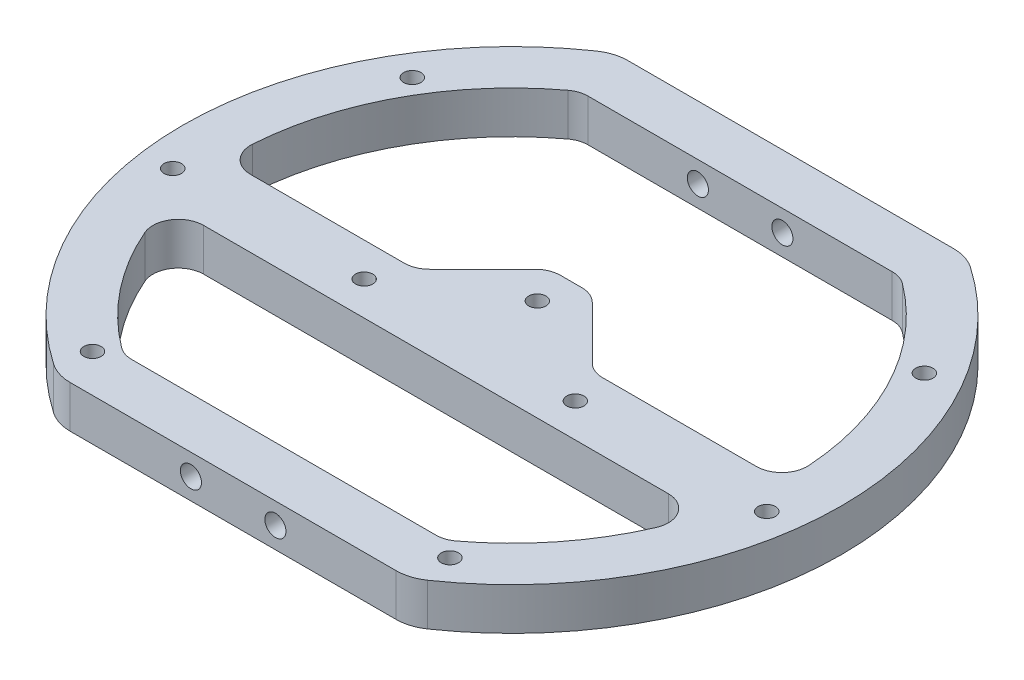
from build123d import *

# Parameters (mm, degrees)
BOSS_EXTRUDE1_DEPTH            = 5
FILLET1_R                      = 5
M3X0_5_TAPPED_HOLE1_AT_2_COUNT = 2
M3X0_5_TAPPED_HOLE1_AT_2_PITCH = 10
M2_5X0_45_TAPPED_HOLE2_D       = 2.05
CUT_EXTRUDE1_DEPTH             = 5
FILLET2_R                      = 3
M2_5X0_45_TAPPED_HOLE1_D       = 2.05


with BuildPart() as part:
    # Sketch1 → Boss-Extrude1 (new body)
    with BuildSketch(Plane(origin=(0, 0, 0), x_dir=(1, 0, 0), z_dir=(0, 1, 0))):
        with BuildLine():
            Line((-20.784609691, 33), (20.784609691, 33))
            ThreePointArc((20.784609691, 33), (39, 0), (20.784609691, -33))
            Line((20.784609691, -33), (-20.784609691, -33))
            ThreePointArc((-20.784609691, -33), (-39, 0), (-20.784609691, 33))
        make_face()
    extrude(amount=BOSS_EXTRUDE1_DEPTH)

    # Fillet1
    fillet1_edges = [part.edges().sort_by_distance(p)[0] for p in [
        (-20.784609691, 2.5, -33),
        (20.784609691, 2.5, -33),
        (20.784609691, 2.5, 33),
        (-20.784609691, 2.5, 33),
    ]]
    fillet(fillet1_edges, radius=FILLET1_R)

    # Sketch3 → M3x0.5 Tapped Hole1 (revolve, cut)
    with BuildSketch(Plane(origin=(-5, 2.5, 33), x_dir=(0, -1, 0), z_dir=(1, 0, 0))):
        Polygon((0, 0), (0, 8.251075774), (1.25, 7.5), (1.25, 0), align=None)
    m3x0_5_tapped_hole1 = revolve(axis=Axis((-5, 2.5, 39.35), (0, 0, -1)), mode=Mode.SUBTRACT)

    # M3x0.5 Tapped Hole1 at 2: M3x0.5 Tapped Hole1 ×2
    with Locations(*[(i * M3X0_5_TAPPED_HOLE1_AT_2_PITCH, 0, 0) for i in range(1, M3X0_5_TAPPED_HOLE1_AT_2_COUNT)]):
        add(m3x0_5_tapped_hole1, mode=Mode.SUBTRACT)

    # Mirror1: M3x0.5 Tapped Hole1 across plane
    add(m3x0_5_tapped_hole1.mirror(Plane.XY), mode=Mode.SUBTRACT)

    # Mirror1 copy 1 sketch → Mirror1 copy 1 (revolve, cut)
    with BuildSketch(Plane(origin=(5, 2.5, -33), x_dir=(0, -1, 0), z_dir=(1, 0, 0))):
        Polygon((0, 0), (0, -8.251075774), (1.25, -7.5), (1.25, 0), align=None)
    revolve(axis=Axis((5, 2.5, -39.35), (0, 0, -1)), mode=Mode.SUBTRACT)

    # M2.5x0.45 Tapped Hole2 (through all)
    with Locations(Plane(origin=(0, 0, 0), x_dir=(-1, 0, 0), z_dir=(0, -1, 0))):
        with Locations((12.5, -5), (-12.5, -5), (0, 3)):
            Hole(M2_5X0_45_TAPPED_HOLE2_D / 2)

    # Sketch6 → Cut-Extrude1 (cut)
    with BuildSketch(Plane.XZ):
        with BuildLine():
            Line((-31.749015733, 9), (31.749015733, 9))
            ThreePointArc((31.749015733, 9), (26.910919894, 19.099800796), (18.973665961, 27))
            Line((18.973665961, 27), (-18.973665961, 27))
            ThreePointArc((-18.973665961, 27), (-26.910919894, 19.099800796), (-31.749015733, 9))
        make_face()
        with BuildLine():
            Line((32.984845005, 1), (10.5, 1))
            Line((10.5, 1), (2.5, -7))
            Line((2.5, -7), (-2.5, -7))
            Line((-2.5, -7), (-10.5, 1))
            Line((-10.5, 1), (-32.984845005, 1))
            ThreePointArc((-32.984845005, 1), (-29.511382812, -14.767473872), (-18.973665961, -27))
            Line((-18.973665961, -27), (18.973665961, -27))
            ThreePointArc((18.973665961, -27), (29.511382812, -14.767473872), (32.984845005, 1))
        make_face()
    extrude(amount=-CUT_EXTRUDE1_DEPTH, mode=Mode.SUBTRACT)

    # Fillet2
    fillet2_edges = [part.edges().sort_by_distance(p)[0] for p in [
        (10.5, 2.5, 1),
        (2.5, 2.5, -7),
        (-2.5, 2.5, -7),
        (-10.5, 2.5, 1),
        (-32.984845005, 2.5, 1),
        (-18.973665961, 2.5, -27),
        (32.984845005, 2.5, 1),
        (-18.973665961, 2.5, 27),
        (31.749015733, 2.5, 9),
        (18.973665961, 2.5, 27),
        (-31.749015733, 2.5, 9),
        (18.973665961, 2.5, -27),
    ]]
    fillet(fillet2_edges, radius=FILLET2_R)

    # M2.5x0.45 Tapped Hole1 (through all)
    with Locations(Plane(origin=(0, 0, 0), x_dir=(-1, 0, 0), z_dir=(0, -1, 0))):
        with Locations((-21.15, -28.5), (21.15, -28.5), (30.3, 18.5), (-30.3, 18.5), (-35.15, -5), (35.15, -5)):
            Hole(M2_5X0_45_TAPPED_HOLE1_D / 2)


solid = part.part
